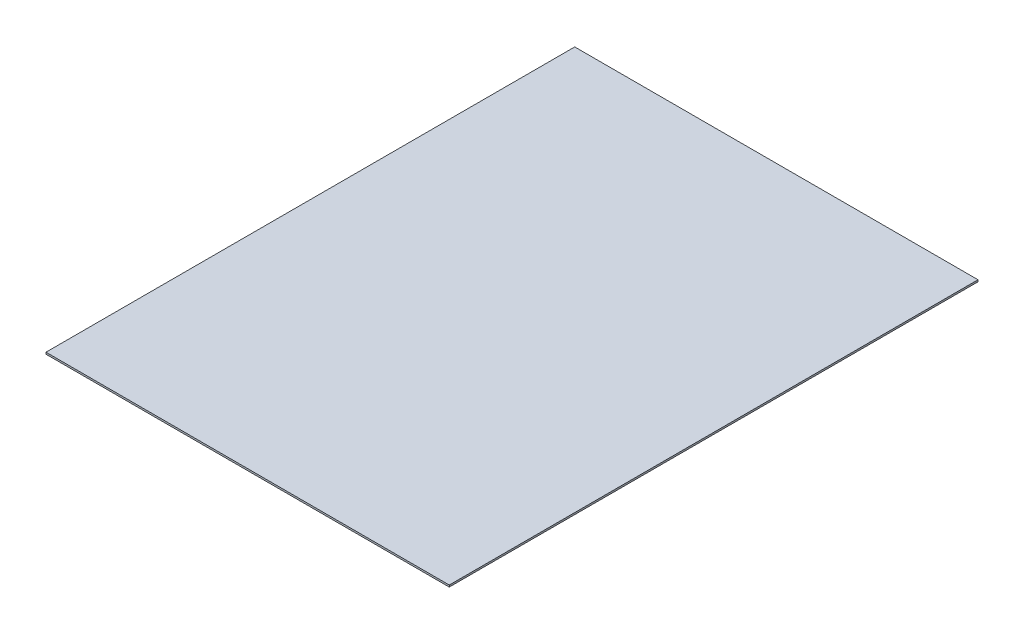
from build123d import *

# Parameters (mm, degrees)
SKETCH1_W           = 450
SKETCH1_H           = 590
BOSS_EXTRUDE1_DEPTH = 2


with BuildPart() as part:
    # Sketch1 → Boss-Extrude1 (new body)
    with BuildSketch(Plane(origin=(0, 0, 0), x_dir=(1, 0, 0), z_dir=(0, 1, 0))):
        Rectangle(SKETCH1_W, SKETCH1_H)
    extrude(amount=BOSS_EXTRUDE1_DEPTH)


solid = part.part
